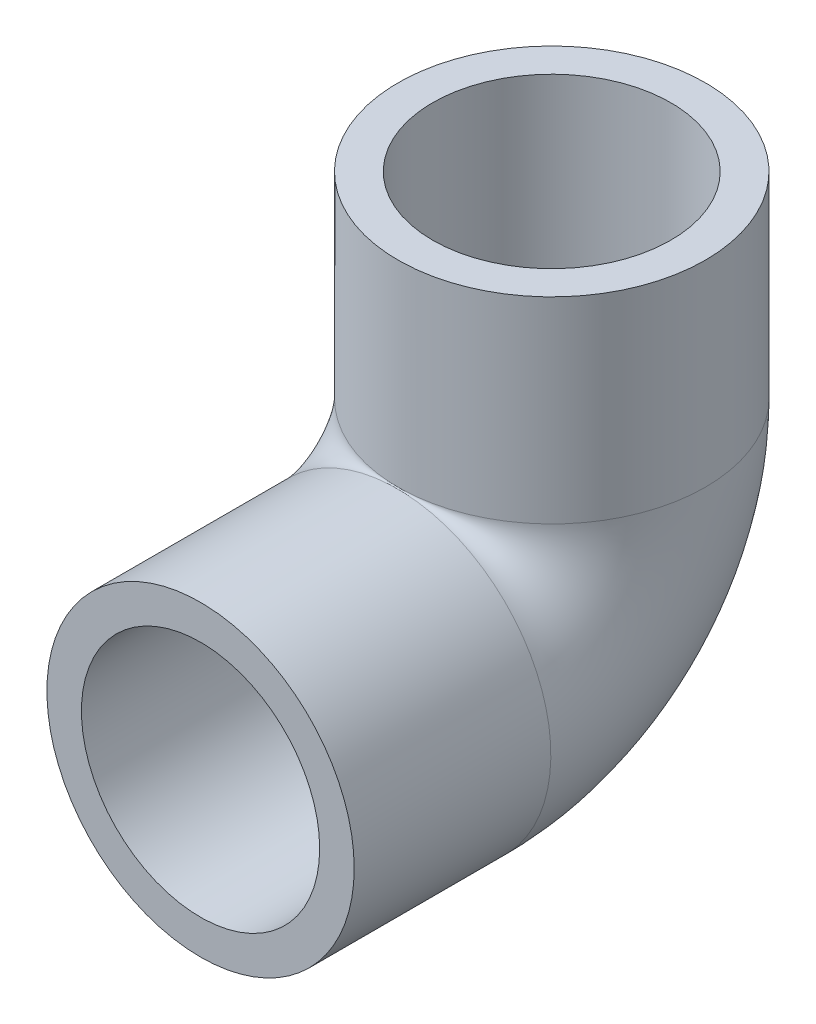
from build123d import *

# Parameters (mm, degrees)
SKETCH1_R          = 13.890625
SKETCH1_R_2        = 8.89
SKETCH3_R          = 10.7696
CUT_EXTRUDE1_DEPTH = 19.05
SKETCH4_R          = 10.7696
CUT_EXTRUDE2_DEPTH = 19.05


with BuildPart() as part:
    # Sweep1: sweep along a path in Sketch2
    with BuildLine(Plane(origin=(0, 0, 0), x_dir=(0, 0, -1), z_dir=(1, 0, 0))) as sweep1_path:
        Line((0, 0), (17.78, 0))
        ThreePointArc((17.78, 0), (27.658281733, 4.091718267), (31.75, 13.97))
        Line((31.75, 13.97), (31.75, 31.75))
    # Sketch1 → Sweep1 (sweep)
    with BuildSketch(Plane.XY):
        Circle(SKETCH1_R)
        Circle(SKETCH1_R_2, mode=Mode.SUBTRACT)
    sweep(path=sweep1_path.line)

    # Sketch3 → Cut-Extrude1 (cut)
    with BuildSketch(Plane.XY):
        Circle(SKETCH3_R)
    extrude(amount=-CUT_EXTRUDE1_DEPTH, mode=Mode.SUBTRACT)

    # Sketch4 → Cut-Extrude2 (cut)
    with BuildSketch(Plane(origin=(0, 31.75, 0), x_dir=(1, 0, 0), z_dir=(0, 1, 0))):
        with Locations((0, 31.75)):
            Circle(SKETCH4_R)
    extrude(amount=-CUT_EXTRUDE2_DEPTH, mode=Mode.SUBTRACT)


solid = part.part
